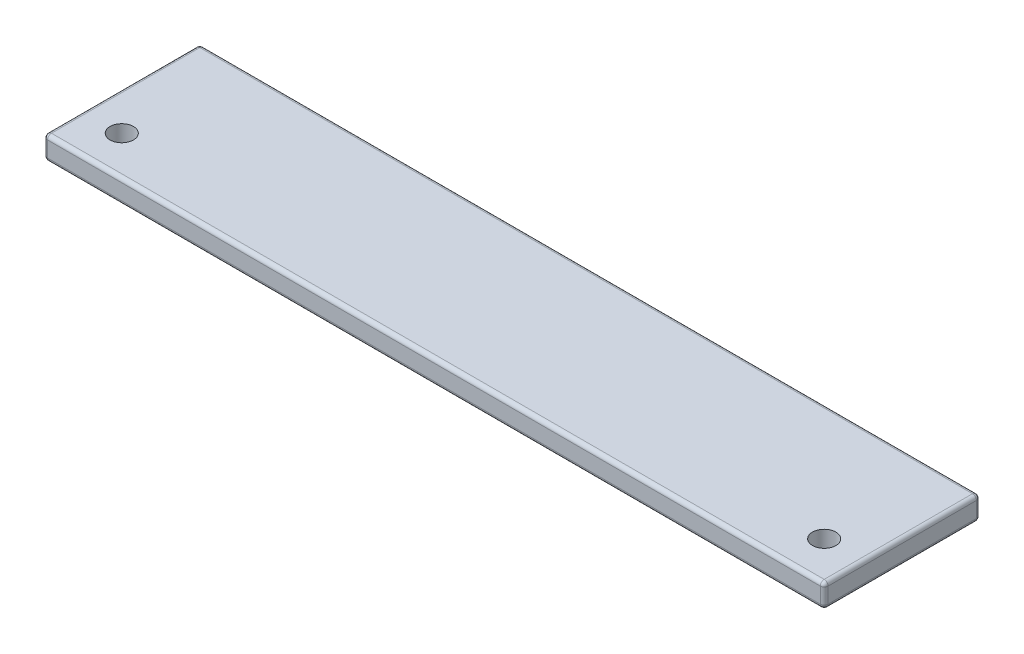
from build123d import *

# Parameters (mm, degrees)
SKETCH1_W           = 100
SKETCH1_H           = 20
BOSS_EXTRUDE1_DEPTH = 3
FILLET1_R           = 0.5
SKETCH2_R           = 1.5
CUT_EXTRUDE1_DEPTH  = 4


with BuildPart() as part:
    # Sketch1 → Boss-Extrude1 (new body)
    with BuildSketch(Plane(origin=(0, 0, 0), x_dir=(1, 0, 0), z_dir=(0, 1, 0))):
        Rectangle(SKETCH1_W, SKETCH1_H)
    extrude(amount=BOSS_EXTRUDE1_DEPTH)

    # Fillet1
    fillet1_edges = [part.edges().sort_by_distance(p)[0] for p in [
        (50, 3, 0),
        (0, 3, -10),
        (-50, 3, 0),
        (0, 0, -10),
        (50, 0, 0),
        (0, 0, 10),
        (-50, 0, 0),
        (0, 3, 10),
        (-50, 1.5, -10),
        (50, 1.5, -10),
        (50, 1.5, 10),
        (-50, 1.5, 10),
    ]]
    fillet(fillet1_edges, radius=FILLET1_R)

    # Sketch2 → Cut-Extrude1 (cut, through all)
    with BuildSketch(Plane.XZ):
        with Locations((45, 5)):
            Circle(SKETCH2_R)
    cut_extrude1 = extrude(amount=-CUT_EXTRUDE1_DEPTH, mode=Mode.SUBTRACT)

    # Mirror1: Cut-Extrude1 across plane
    add(cut_extrude1.mirror(Plane(origin=(0, 0, 0), x_dir=(0, 0, 1), z_dir=(1, 0, 0))), mode=Mode.SUBTRACT)


solid = part.part
